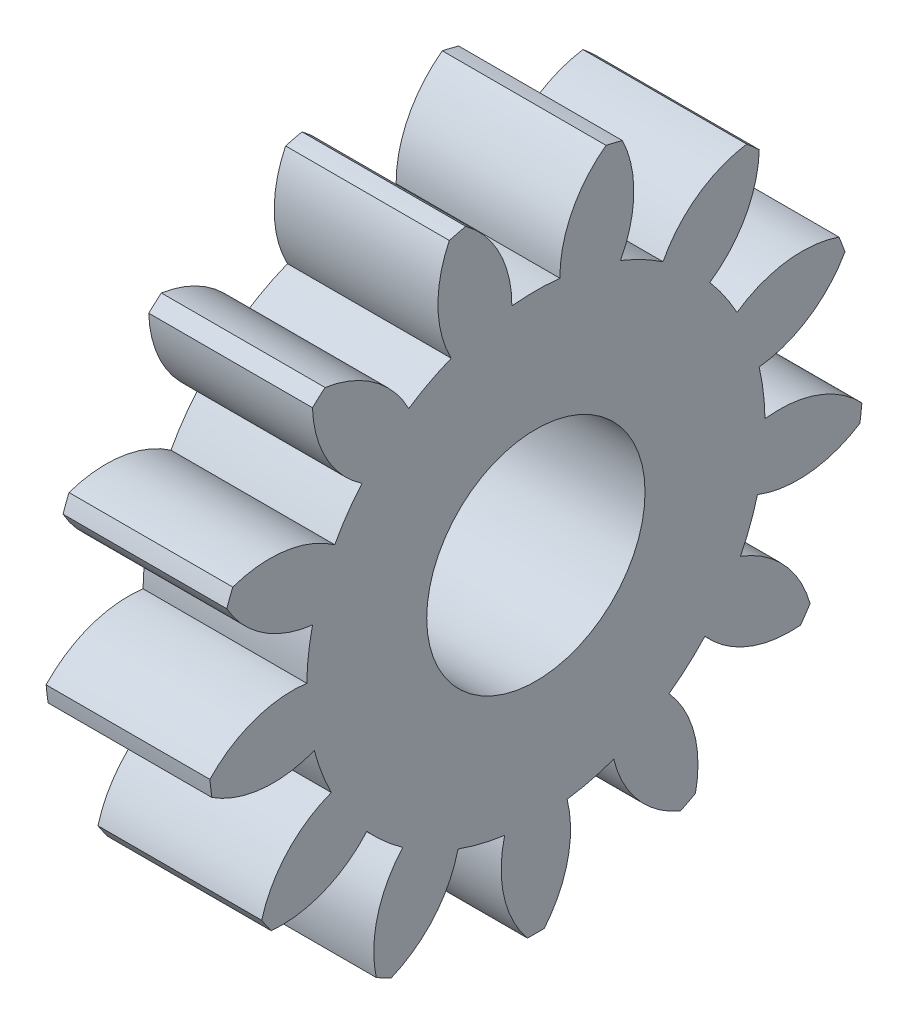
from build123d import *

# Parameters (mm, degrees)
BASPROSKE_W     = 1.5
BASPROSKE_H     = 3
TOOTHCUT_DEPTH  = 5.5
TEETHCUTS_COUNT = 13
TEETHCUTS_ANGLE = 332.307692308
BORSKE_R        = 1
BORE_DEPTH      = 50.0000508


with BuildPart() as part:
    # BasProSke → Base-Revolve (revolve)
    with BuildSketch(Plane(origin=(0, 0, 0), x_dir=(1, 0, 0), z_dir=(0, 1, 0)), mode=Mode.PRIVATE) as base_revolve_sk:
        with Locations((0.75, 1.5)):
            Rectangle(BASPROSKE_W, BASPROSKE_H)
    revolve(base_revolve_sk.sketch.rotate(Axis((-10, 0, 0), (1, 0, 0)), 180), axis=Axis((-10, 0, 0), (1, 0, 0)))

    # TooCutSke → ToothCut (cut, through all)
    with BuildSketch(Plane(origin=(0, 0, 0), x_dir=(0, 0, -1), z_dir=(1, 0, 0))):
        with BuildLine():
            ThreePointArc((0.219916266, 2.087447685), (0, 2.099), (-0.219916266, 2.087447685))
            ThreePointArc((-0.219916266, 2.087447685), (-0.338063769, 2.574769791), (-0.670512305, 2.950162438))
            ThreePointArc((-0.670512305, 2.950162438), (0, 3.0254), (0.670512305, 2.950162438))
            ThreePointArc((0.670512305, 2.950162438), (0.338063769, 2.574769791), (0.219916266, 2.087447685))
        make_face()
    toothcut = extrude(amount=TOOTHCUT_DEPTH, mode=Mode.SUBTRACT)

    # TeethCuts: ToothCut ×13 about axis
    teethcuts_axis = Axis((-10, 0, 0), (1, 0, 0))
    for i in range(1, TEETHCUTS_COUNT):
        add(toothcut.rotate(teethcuts_axis, i * TEETHCUTS_ANGLE / (TEETHCUTS_COUNT - 1)), mode=Mode.SUBTRACT)

    # BorSke → Bore (cut, symmetric)
    with BuildSketch(Plane(origin=(0, 0, 0), x_dir=(0, 0, -1), z_dir=(1, 0, 0))):
        with Locations(Location((0, 0, 0), (0, 0, 180))):
            Circle(BORSKE_R)
    extrude(amount=BORE_DEPTH, both=True, mode=Mode.SUBTRACT)


solid = part.part
